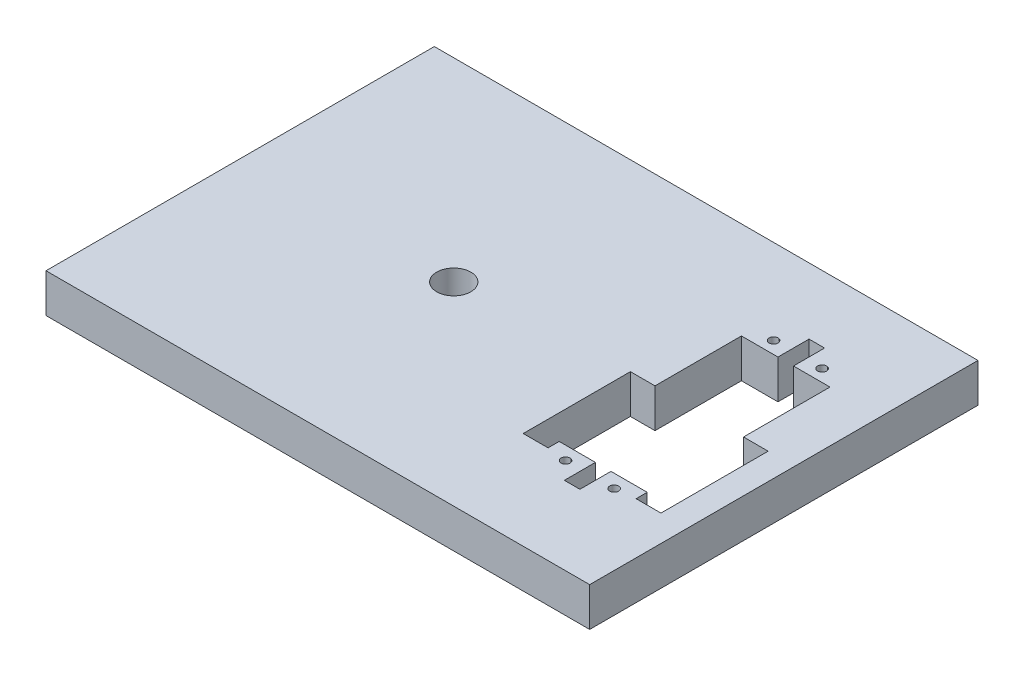
from build123d import *

# Parameters (mm, degrees)
SKETCH1_W           = 177.8
SKETCH1_H           = 127
SKETCH1_R           = 5.588
SKETCH1_R_2         = 1.4605
SKETCH1_W_2         = 28.956
SKETCH1_H_2         = 59.69
BOSS_EXTRUDE1_DEPTH = 12.7
SKETCH3_W           = 8.128
SKETCH3_H           = 35.052
SKETCH3_W_2         = 5.08
SKETCH3_H_2         = 10.16
CUT_EXTRUDE3_DEPTH  = 13.7


with BuildPart() as part:
    # Sketch1 → Boss-Extrude1 (new body)
    with BuildSketch(Plane(origin=(0, 0, 0), x_dir=(1, 0, 0), z_dir=(0, 1, 0))):
        Rectangle(SKETCH1_W, SKETCH1_H)
        with Locations((-19.05, 0)):
            Circle(SKETCH1_R, mode=Mode.SUBTRACT)
        with Locations((49.825565695, -32.301655548)):
            Circle(SKETCH1_R_2, mode=Mode.SUBTRACT)
        with Locations((65.700565695, -32.301655548)):
            Circle(SKETCH1_R_2, mode=Mode.SUBTRACT)
        with Locations((49.825565695, 35.719544452)):
            Circle(SKETCH1_R_2, mode=Mode.SUBTRACT)
        with Locations((65.700565695, 35.719544452)):
            Circle(SKETCH1_R_2, mode=Mode.SUBTRACT)
        with Locations((57.763065695, 1.908969452)):
            Rectangle(SKETCH1_W_2, SKETCH1_H_2, mode=Mode.SUBTRACT)
    extrude(amount=BOSS_EXTRUDE1_DEPTH)

    # Sketch3 → Cut-Extrude3 (cut, through all)
    with BuildSketch(Plane(origin=(0, 0, 0), x_dir=(1, 0, 0), z_dir=(0, 1, 0))):
        with Locations((39.301988782, -14.045405548)):
            Rectangle(SKETCH3_W, SKETCH3_H)
        with Locations((76.224142608, -14.045405548)):
            Rectangle(SKETCH3_W, SKETCH3_H)
        with Locations((57.763065695, -33.016030548)):
            Rectangle(SKETCH3_W_2, SKETCH3_H_2)
        with Locations((57.763065695, 36.833969452)):
            Rectangle(SKETCH3_W_2, SKETCH3_H_2)
    extrude(amount=CUT_EXTRUDE3_DEPTH, mode=Mode.SUBTRACT)


solid = part.part
